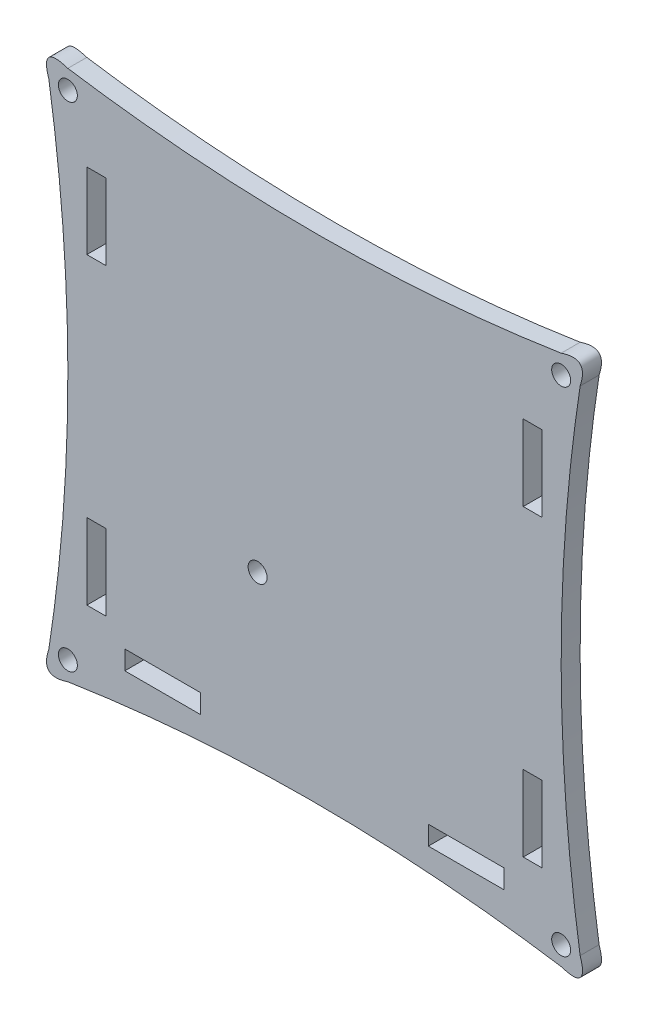
from build123d import *

# Parameters (mm, degrees)
SKETCH1_W           = 6.35
SKETCH1_H           = 25.4
SKETCH1_W_2         = 25.4
SKETCH1_H_2         = 6.35
BOSS_EXTRUDE1_DEPTH = 6.35
SKETCH2_R           = 3.175
CUT_EXTRUDE2_DEPTH  = 6.35
SKETCH3_R           = 3.175
CUT_EXTRUDE3_DEPTH  = 6.35


with BuildPart() as part:
    # Sketch1 → Boss-Extrude1 (new body)
    with BuildSketch(Plane.XY):
        with BuildLine():
            add(Edge.make_bspline(
                [(0, 171.45), (12.7, 88.9), (0, 6.35)],
                knots=[0, 0, 0, 1, 1, 1], degree=2))
            add(Edge.make_bspline(
                [(0, 6.35), (-3.175, -3.175), (6.35, 0)],
                knots=[0, 0, 0, 1, 1, 1], degree=2))
            add(Edge.make_bspline(
                [(6.35, 0), (88.9, 12.7), (171.45, 0)],
                knots=[0, 0, 0, 1, 1, 1], degree=2))
            add(Edge.make_bspline(
                [(177.8, 6.35), (180.975, -3.175), (171.45, 0)],
                knots=[0, 0, 0, 1, 1, 1], degree=2))
            add(Edge.make_bspline(
                [(177.8, 171.45), (165.1, 88.9), (177.8, 6.35)],
                knots=[0, 0, 0, 1, 1, 1], degree=2))
            add(Edge.make_bspline(
                [(171.45, 177.8), (180.975, 180.975), (177.8, 171.45)],
                knots=[0, 0, 0, 1, 1, 1], degree=2))
            add(Edge.make_bspline(
                [(6.35, 177.8), (88.9, 165.1), (171.45, 177.8)],
                knots=[0, 0, 0, 1, 1, 1], degree=2))
            add(Edge.make_bspline(
                [(0, 171.45), (-3.175, 180.975), (6.35, 177.8)],
                knots=[0, 0, 0, 1, 1, 1], degree=2))
        make_face()
        with Locations((15.875, 38.1)):
            Rectangle(SKETCH1_W, SKETCH1_H, mode=Mode.SUBTRACT)
        with Locations((38.1, 15.875)):
            Rectangle(SKETCH1_W_2, SKETCH1_H_2, mode=Mode.SUBTRACT)
        with Locations((15.875, 139.7)):
            Rectangle(SKETCH1_W, SKETCH1_H, mode=Mode.SUBTRACT)
        with Locations((161.925, 139.7)):
            Rectangle(SKETCH1_W, SKETCH1_H, mode=Mode.SUBTRACT)
        with Locations((139.7, 15.875)):
            Rectangle(SKETCH1_W_2, SKETCH1_H_2, mode=Mode.SUBTRACT)
        with Locations((161.925, 38.1)):
            Rectangle(SKETCH1_W, SKETCH1_H, mode=Mode.SUBTRACT)
    extrude(amount=BOSS_EXTRUDE1_DEPTH)

    # Sketch2 → Cut-Extrude2 (cut)
    with BuildSketch(Plane.XY.offset(6.35)):
        with Locations((69.85, 63.5)):
            Circle(SKETCH2_R)
    extrude(amount=-CUT_EXTRUDE2_DEPTH, mode=Mode.SUBTRACT)

    # Sketch3 → Cut-Extrude3 (cut)
    with BuildSketch(Plane.XY.offset(6.35)):
        with Locations((6.35, 6.35)):
            Circle(SKETCH3_R)
        with Locations((171.45, 6.35)):
            Circle(SKETCH3_R)
        with Locations((6.35, 171.45)):
            Circle(SKETCH3_R)
        with Locations((171.45, 171.45)):
            Circle(SKETCH3_R)
    extrude(amount=-CUT_EXTRUDE3_DEPTH, mode=Mode.SUBTRACT)


solid = part.part
